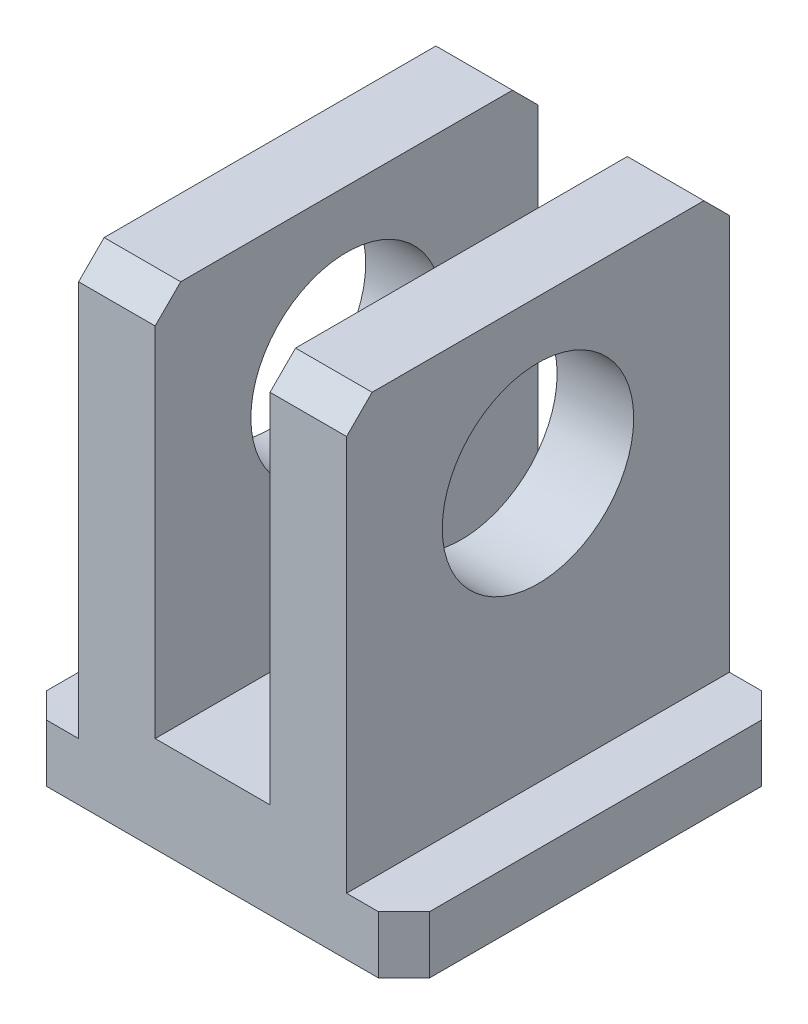
from build123d import *

# Parameters (mm, degrees)
SKETCH_1_W          = 30
SKETCH_1_H          = 37.5
EXTRUDE_1_DEPTH     = 15
CHAMFER_1_SIZE      = 2
CUT_EXTRUDE_1_REACH = 32
SKETCH_2_W          = 4.5
SKETCH_2_H          = 33
SKETCH_2_W_2        = 9
SKETCH_2_H_2        = 30
SKETCH_3_R          = 7.5
CUT_EXTRUDE_2_DEPTH = 10.5
CHAMFER_2_SIZE      = 2


with BuildPart() as part:
    # 스케치1 → 보스-돌출1 (new body, symmetric)
    with BuildSketch(Plane(origin=(0, 0, 0), x_dir=(0, 0, -1), z_dir=(1, 0, 0))):
        with Locations((15, 18.75)):
            Rectangle(SKETCH_1_W, SKETCH_1_H)
    extrude(amount=EXTRUDE_1_DEPTH, both=True)

    # 모따기1
    chamfer_1_edges = [part.edges().sort_by_distance(p)[0] for p in [
        (0, 37.5, 0),
        (0, 37.5, -30),
    ]]
    chamfer(chamfer_1_edges, length=CHAMFER_1_SIZE)

    # 스케치2 → 컷-돌출1 (cut, up to next)
    with BuildSketch(Plane.XY, mode=Mode.PRIVATE) as cut_extrude_1_sk1:
        with Locations((-12.75, 21)):
            Rectangle(SKETCH_2_W, SKETCH_2_H)
    cut_extrude_1_tool1 = extrude(cut_extrude_1_sk1.sketch, amount=-CUT_EXTRUDE_1_REACH, mode=Mode.PRIVATE) & part.part
    add(cut_extrude_1_tool1.solids().sort_by_distance((-12.75, 21, 0))[0], mode=Mode.SUBTRACT)
    # 스케치2 → 컷-돌출1 (cut, up to next)
    with BuildSketch(Plane.XY, mode=Mode.PRIVATE) as cut_extrude_1_sk2:
        with Locations((12.75, 21)):
            Rectangle(SKETCH_2_W, SKETCH_2_H)
    cut_extrude_1_tool2 = extrude(cut_extrude_1_sk2.sketch, amount=-CUT_EXTRUDE_1_REACH, mode=Mode.PRIVATE) & part.part
    add(cut_extrude_1_tool2.solids().sort_by_distance((12.75, 21, 0))[0], mode=Mode.SUBTRACT)
    # 스케치2 → 컷-돌출1 (cut, up to next)
    with BuildSketch(Plane.XY, mode=Mode.PRIVATE) as cut_extrude_1_sk3:
        with Locations((0, 22.5)):
            Rectangle(SKETCH_2_W_2, SKETCH_2_H_2)
    cut_extrude_1_tool3 = extrude(cut_extrude_1_sk3.sketch, amount=-CUT_EXTRUDE_1_REACH, mode=Mode.PRIVATE) & part.part
    add(cut_extrude_1_tool3.solids().sort_by_distance((0, 22.5, 0))[0], mode=Mode.SUBTRACT)

    # 스케치3 → 컷-돌출2 (cut, symmetric)
    with BuildSketch(Plane(origin=(0, 0, 0), x_dir=(0, 0, -1), z_dir=(1, 0, 0))):
        with Locations((15, 25.5)):
            Circle(SKETCH_3_R)
    extrude(amount=CUT_EXTRUDE_2_DEPTH, both=True, mode=Mode.SUBTRACT)

    # 모따기2
    chamfer_2_edges = [part.edges().sort_by_distance(p)[0] for p in [
        (15, 2.25, -30),
        (-15, 2.25, 0),
        (15, 2.25, 0),
        (-15, 2.25, -30),
    ]]
    chamfer(chamfer_2_edges, length=CHAMFER_2_SIZE)


solid = part.part
